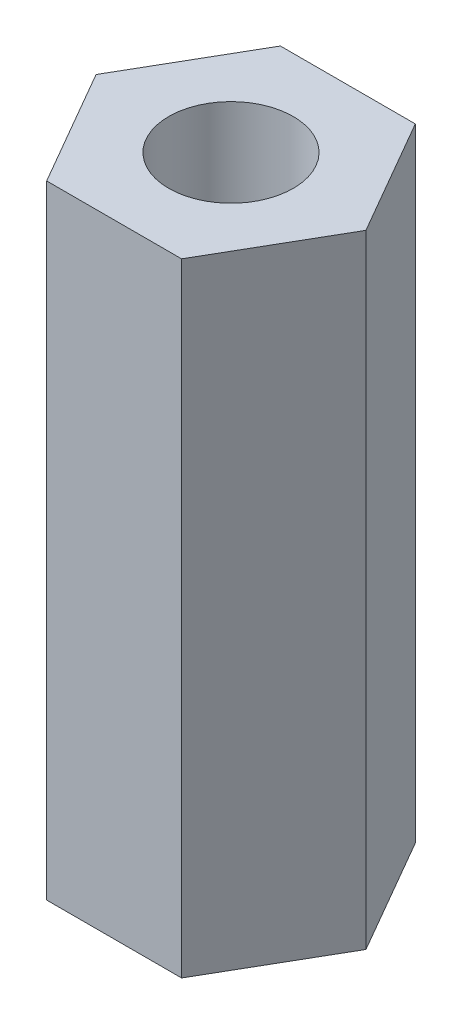
from build123d import *

# Parameters (mm, degrees)
SKETCH_2_R      = 1.5
EXTRUDE_1_DEPTH = 15


with BuildPart() as part:
    # 草图2 → 凸台-拉伸1 (new body)
    with BuildSketch(Plane(origin=(0, 0, 0), x_dir=(1, 0, 0), z_dir=(0, 1, 0))):
        Polygon((-1.625, 2.814582562), (-3.25, 0), (-1.625, -2.814582562), (1.625, -2.814582562), (3.25, 0), (1.625, 2.814582562), align=None)
        Circle(SKETCH_2_R, mode=Mode.SUBTRACT)
    extrude(amount=EXTRUDE_1_DEPTH)


solid = part.part
